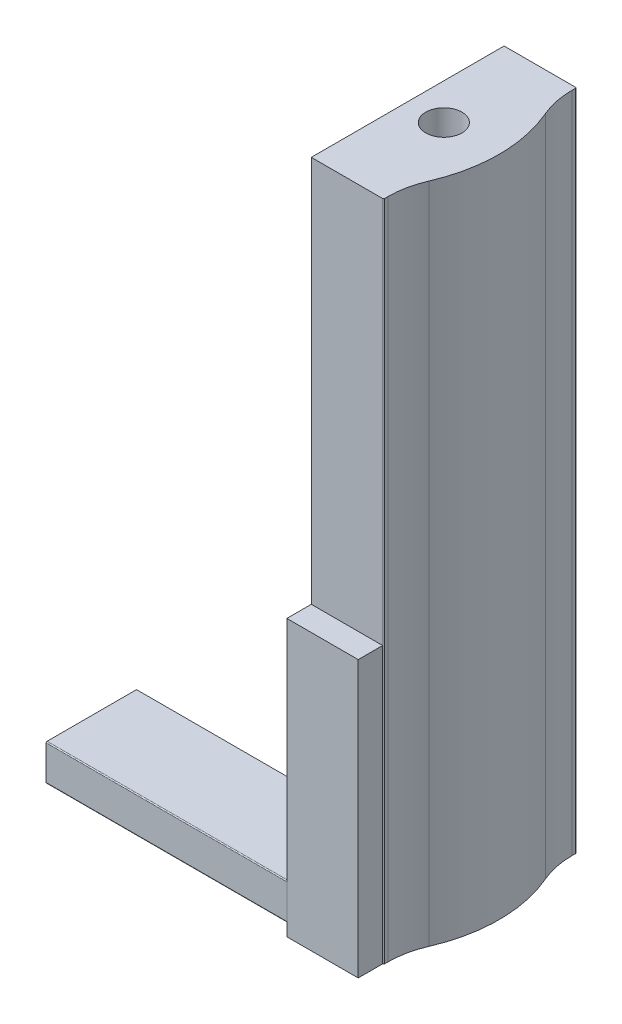
from build123d import *

# Parameters (mm, degrees)
SKETCH1_R           = 1.190625
BOSS_EXTRUDE4_DEPTH = 43.65625
BOSS_EXTRUDE5_DEPTH = 15.875
SKETCH7_W           = 4.699305321
SKETCH7_H           = 1.609279132
BOSS_EXTRUDE6_DEPTH = 18.161


with BuildPart() as part:
    # Sketch1 → Boss-Extrude4 (new body)
    with BuildSketch(Plane(origin=(0, 0, 0), x_dir=(1, 0, 0), z_dir=(0, 1, 0))):
        with BuildLine():
            ThreePointArc((1.961121792, 5.783909674), (1.616585512, 6.873597745), (1.500127735, 8.01050712))
            Line((1.500127735, 8.01050712), (1.500127735, 8.234009675))
            ThreePointArc((1.500127735, 8.234009675), (1.481529016, 8.278910955), (1.436627735, 8.297509675))
            Line((1.436627735, 8.297509675), (-2.865497265, 8.297509675))
            Line((-2.865497265, 8.297509675), (-3.262372265, 8.297509675))
            Line((-3.262372265, 8.297509675), (-3.262372265, 7.900634675))
            Line((-3.262372265, 7.900634675), (-3.262372265, -4.005615325))
            Line((-3.262372265, -4.005615325), (-3.262372265, -4.402490325))
            Line((-3.262372265, -4.402490325), (-2.865497265, -4.402490325))
            Line((-2.865497265, -4.402490325), (1.436627735, -4.402490325))
            ThreePointArc((1.436627735, -4.402490325), (1.481529016, -4.383891606), (1.500127735, -4.338990325))
            Line((1.500127735, -4.338990325), (1.500127735, -4.11548777))
            ThreePointArc((1.500127735, -4.11548777), (1.616585512, -2.978578396), (1.961121792, -1.888890325))
            ThreePointArc((1.961121792, -1.888890325), (2.755408878, 1.947509675), (1.961121792, 5.783909674))
        make_face()
        with Locations((-0.881122265, 1.947509675)):
            Circle(SKETCH1_R, mode=Mode.SUBTRACT)
    extrude(amount=BOSS_EXTRUDE4_DEPTH)

    # Sketch6 → Boss-Extrude5 (add)
    with BuildSketch(Plane.ZY.offset(3.262372265)):
        with BuildLine():
            Line((0.036865325, 3.175), (5.926490325, 3.175))
            ThreePointArc((5.926490325, 3.175), (5.971391606, 3.156401281), (5.989990325, 3.1115))
            Line((5.989990325, 3.1115), (5.989990325, 0.85725))
            ThreePointArc((5.989990325, 0.85725), (5.971391606, 0.812348719), (5.926490325, 0.79375))
            Line((5.926490325, 0.79375), (0.100365325, 0.79375))
            ThreePointArc((0.100365325, 0.79375), (0.055464045, 0.812348719), (0.036865325, 0.85725))
            Line((0.036865325, 0.85725), (0.036865325, 3.175))
        make_face()
    extrude(amount=BOSS_EXTRUDE5_DEPTH)

    # Sketch7 → Boss-Extrude6 (add)
    with BuildSketch(Plane.XZ):
        with Locations((-0.912719605, 5.207129891)):
            Rectangle(SKETCH7_W, SKETCH7_H)
    extrude(amount=-BOSS_EXTRUDE6_DEPTH)


solid = part.part
